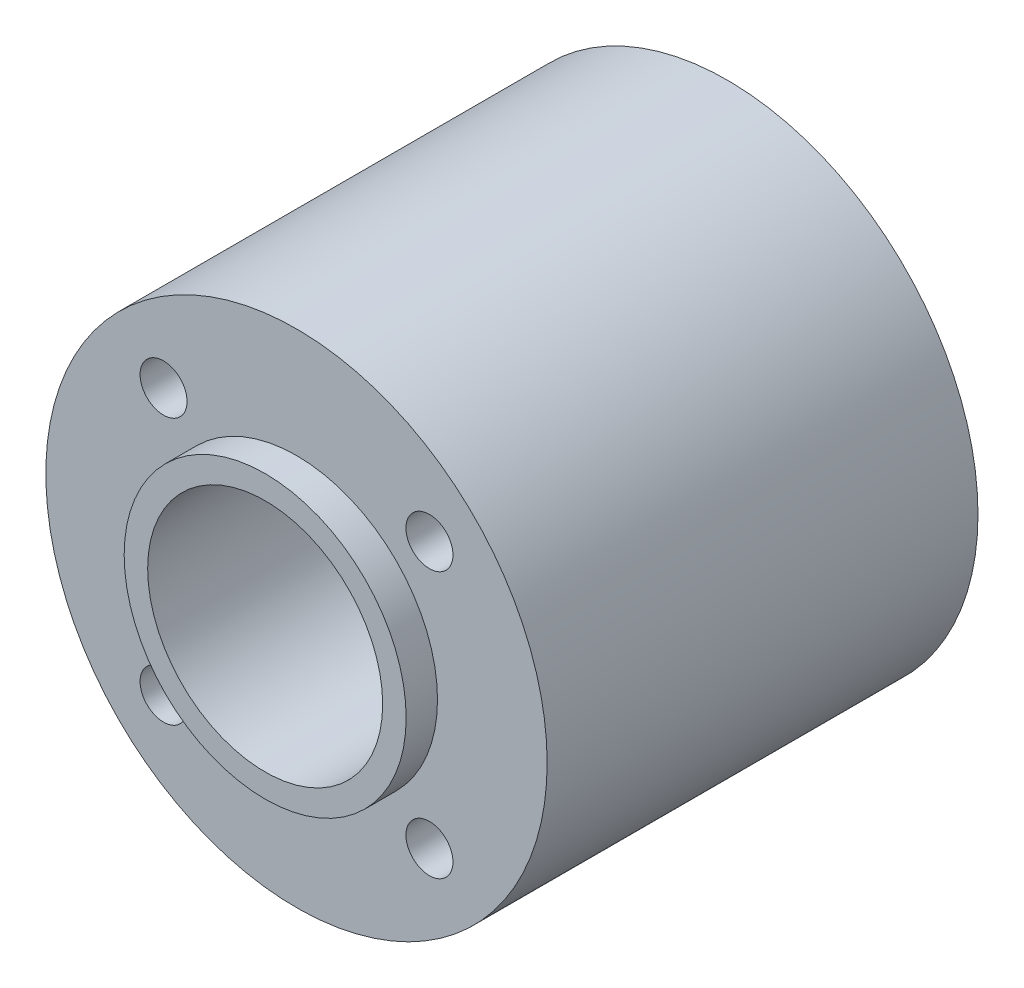
from build123d import *

# Parameters (mm, degrees)
SKETCH1_R           = 32
SKETCH1_R_2         = 18
SKETCH1_R_3         = 15
BOSS_EXTRUDE1_DEPTH = 55
SKETCH1_3_R         = 18
SKETCH1_3_R_2       = 15
BOSS_EXTRUDE2_DEPTH = 4
BOSS_EXTRUDE4_START = -55
SKETCH1_6_R         = 18
SKETCH1_6_R_2       = 15
BOSS_EXTRUDE4_DEPTH = 4
SKETCH2_R           = 3
CUT_EXTRUDE1_DEPTH  = 191


with BuildPart() as part:
    # Sketch1 → Boss-Extrude1 (new body)
    with BuildSketch(Plane.XY):
        Circle(SKETCH1_R)
        Circle(SKETCH1_R_2, mode=Mode.SUBTRACT)
        Circle(SKETCH1_R_2)
        Circle(SKETCH1_R_3, mode=Mode.SUBTRACT)
    extrude(amount=-BOSS_EXTRUDE1_DEPTH)

    # Sketch1_3 → Boss-Extrude2 (add)
    with BuildSketch(Plane.XY):
        Circle(SKETCH1_3_R)
        Circle(SKETCH1_3_R_2, mode=Mode.SUBTRACT)
    extrude(amount=BOSS_EXTRUDE2_DEPTH)

    # Sketch1_6 → Boss-Extrude4 (add)
    with BuildSketch(Plane.XY.offset(BOSS_EXTRUDE4_START)):
        Circle(SKETCH1_6_R)
        Circle(SKETCH1_6_R_2, mode=Mode.SUBTRACT)
    extrude(amount=-BOSS_EXTRUDE4_DEPTH)

    # Sketch2 → Cut-Extrude1 (cut)
    with BuildSketch(Plane.XY):
        with Locations((-16.970562748, 16.970562748)):
            Circle(SKETCH2_R)
        with Locations((16.970562748, 16.970562748)):
            Circle(SKETCH2_R)
        with Locations((16.970562748, -16.970562748)):
            Circle(SKETCH2_R)
        with Locations((-16.970562748, -16.970562748)):
            Circle(SKETCH2_R)
    extrude(amount=-CUT_EXTRUDE1_DEPTH, mode=Mode.SUBTRACT)


solid = part.part
